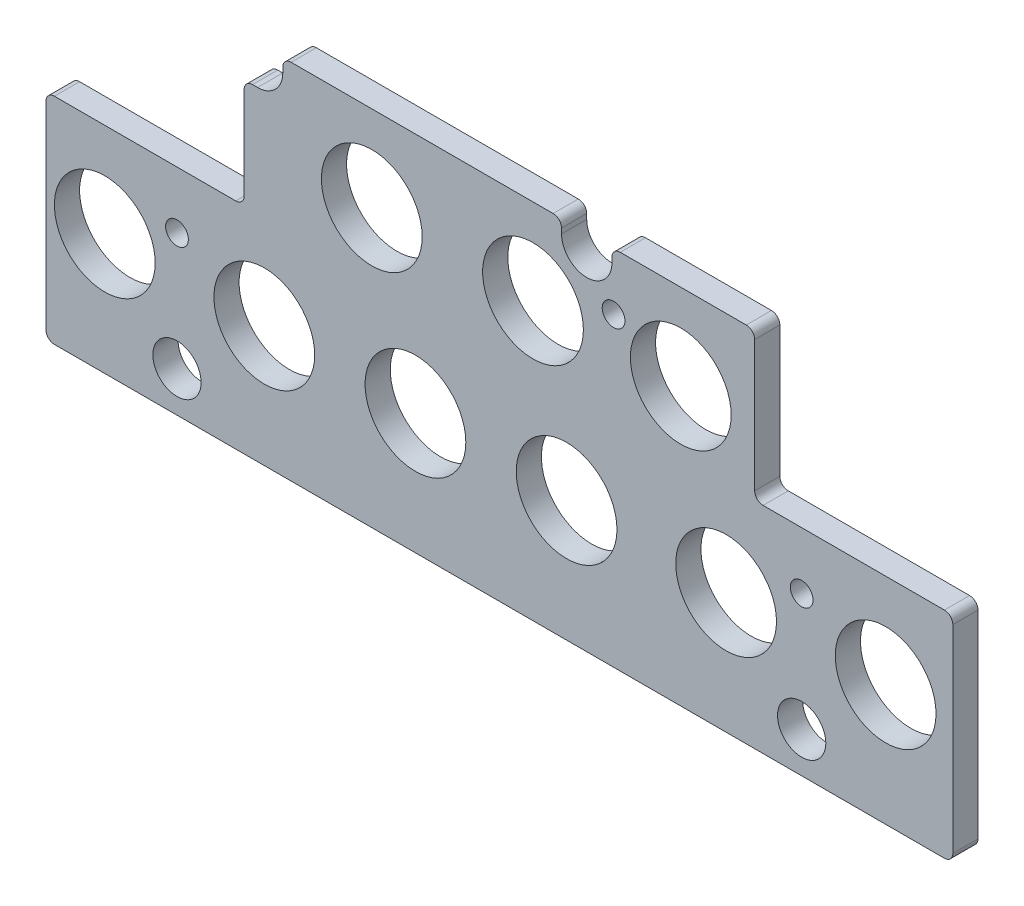
from build123d import *

# Parameters (mm, degrees)
BOSS_EXTRUDE1_DEPTH              = 4.7625
SKETCH3_R                        = 9.525
CUT_EXTRUDE1_DEPTH               = 5.7625
F_6_CLEARANCE_HOLE1_D            = 4.3053
F_23_64_0_35938_DIAMETER_HOLE1_D = 9.128252
FILLET1_R                        = 1.5875


with BuildPart() as part:
    # Sketch1 → Boss-Extrude1 (new body)
    with BuildSketch(Plane.XY):
        with BuildLine():
            Line((-40.9575, 29.810203833), (-40.9575, 27.270203833))
            ThreePointArc((-40.9575, 27.270203833), (-42.352403955, 23.902607788), (-45.72, 22.507703833))
            Line((-45.72, 22.507703833), (-48.26, 22.507703833))
            Line((-48.26, 22.507703833), (-48.26, 1.870203833))
            Line((-48.26, 1.870203833), (-85.725, 1.870203833))
            Line((-85.725, 1.870203833), (-85.725, -38.769796167))
            Line((-85.725, -38.769796167), (85.725, -38.769796167))
            Line((85.725, -38.769796167), (85.725, 1.870203833))
            Line((85.725, 1.870203833), (48.26, 1.870203833))
            Line((48.26, 1.870203833), (48.26, 29.810203833))
            Line((48.26, 29.810203833), (21.2725, 29.810203833))
            Line((21.2725, 29.810203833), (21.2725, 27.270203833))
            ThreePointArc((21.2725, 27.270203833), (16.51, 22.507703833), (11.7475, 27.270203833))
            Line((11.7475, 27.270203833), (11.7475, 29.810203833))
            Line((11.7475, 29.810203833), (-40.9575, 29.810203833))
        make_face()
    extrude(amount=BOSS_EXTRUDE1_DEPTH)

    # Sketch3 → Cut-Extrude1 (cut, through all)
    with BuildSketch(Plane.XY.offset(4.7625)):
        with Locations((73.025, -15.909796167)):
            Circle(SKETCH3_R)
        with Locations((42.8625, -15.909796167)):
            Circle(SKETCH3_R)
        with Locations((12.7, -15.909796167)):
            Circle(SKETCH3_R)
        with Locations((-15.875, -15.909796167)):
            Circle(SKETCH3_R)
        with Locations((-44.45, -15.909796167)):
            Circle(SKETCH3_R)
        with Locations((-74.6125, -15.909796167)):
            Circle(SKETCH3_R)
        with Locations((34.29, 13.617703833)):
            Circle(SKETCH3_R)
        with Locations((6.35, 13.617703833)):
            Circle(SKETCH3_R)
        with Locations((-24.13, 13.617703833)):
            Circle(SKETCH3_R)
    extrude(amount=-CUT_EXTRUDE1_DEPTH, mode=Mode.SUBTRACT)

    # #6 Clearance Hole1 (through all)
    with Locations(Plane.XY.offset(4.7625)):
        with Locations((57.15, -8.924796167), (21.59, 19.015203833), (-60.96, -8.924796167)):
            Hole(F_6_CLEARANCE_HOLE1_D / 2)

    # 23/64 (0.35938) Diameter Hole1 (through all)
    with Locations(Plane.XY.offset(4.7625)):
        with Locations((57.15, -31.149796167), (-60.96, -31.149796167)):
            Hole(F_23_64_0_35938_DIAMETER_HOLE1_D / 2)

    # Fillet1
    fillet1_edges = [part.edges().sort_by_distance(p)[0] for p in [
        (11.7475, 29.810203833, 2.38125),
        (21.2725, 29.810203833, 2.38125),
        (48.26, 29.810203833, 2.38125),
        (48.26, 1.870203833, 2.38125),
        (85.725, 1.870203833, 2.38125),
        (85.725, -38.769796167, 2.38125),
        (-85.725, -38.769796167, 2.38125),
        (-85.725, 1.870203833, 2.38125),
        (-48.26, 1.870203833, 2.38125),
        (-48.26, 22.507703833, 2.38125),
        (-40.9575, 29.810203833, 2.38125),
    ]]
    fillet(fillet1_edges, radius=FILLET1_R)


solid = part.part
